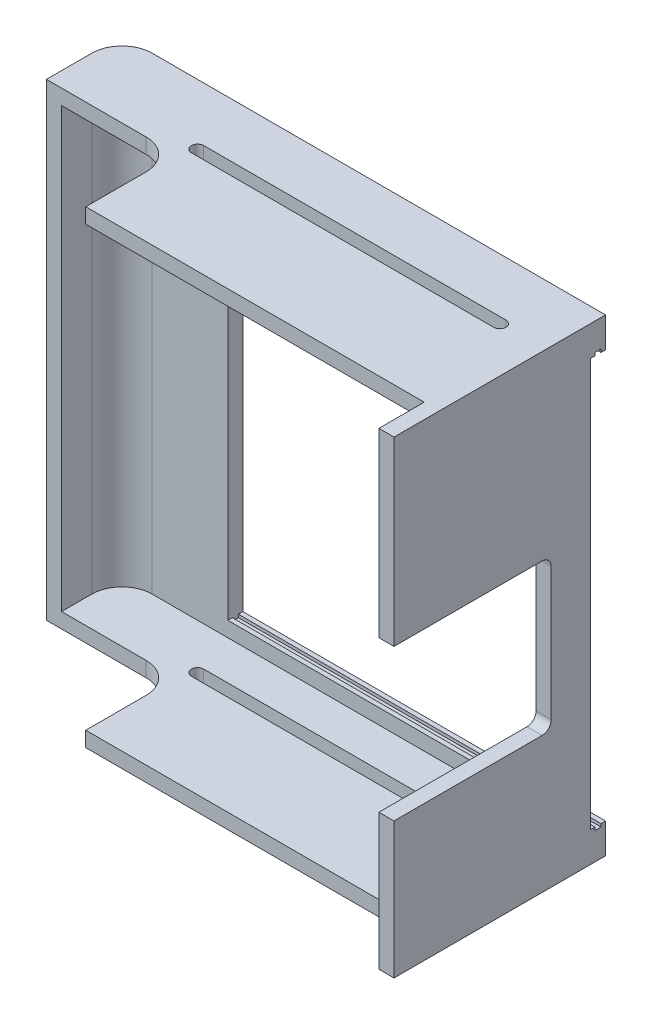
from build123d import *

# Parameters (mm, degrees)
BOSS_EXTRUDE1_DEPTH = 5
SKETCH2_W           = 150
SKETCH2_H           = 5
BOSS_EXTRUDE2_DEPTH = 145
SKETCH6_W           = 70
SKETCH6_H           = 155
BOSS_EXTRUDE3_DEPTH = 5
SKETCH7_W           = 52
SKETCH7_H           = 50
CUT_EXTRUDE1_DEPTH  = 5
SKETCH8_W           = 25
SKETCH8_H           = 155
BOSS_EXTRUDE4_DEPTH = 5
FILLET1_R           = 10
FILLET2_R           = 10
SKETCH9_W           = 2
SKETCH9_H           = 1
CUT_EXTRUDE2_DEPTH  = 120
FILLET5_R           = 3
CUT_EXTRUDE4_START  = -155
CUT_EXTRUDE4_DEPTH  = 155


with BuildPart() as part:
    # Sketch1 → Boss-Extrude1 (new body)
    with BuildSketch(Plane(origin=(0, 0, 0), x_dir=(1, 0, 0), z_dir=(0, 1, 0))):
        Polygon((63.462686567, 36.156716418), (-86.537313433, 36.156716418), (-86.537313433, 11.156716418), (-48.537313433, 11.156716418), (-48.537313433, -18.843283582), (63.462686567, -18.843283582), align=None)
    boss_extrude1 = extrude(amount=BOSS_EXTRUDE1_DEPTH)

    # Sketch2 → Boss-Extrude2 (add)
    with BuildSketch(Plane(origin=(0, 5, 0), x_dir=(1, 0, 0), z_dir=(0, 1, 0))):
        with Locations((-11.537313433, 33.656716418)):
            Rectangle(SKETCH2_W, SKETCH2_H)
    extrude(amount=BOSS_EXTRUDE2_DEPTH)

    # Mirror1: Boss-Extrude1 across plane
    add(boss_extrude1.mirror(Plane.ZX.offset(77.5)))

    # Sketch6 → Boss-Extrude3 (add)
    with BuildSketch(Plane(origin=(63.462686567, 0, 0), x_dir=(0, 0, -1), z_dir=(1, 0, 0))):
        with Locations((1.156716418, 77.5)):
            Rectangle(SKETCH6_W, SKETCH6_H)
    extrude(amount=BOSS_EXTRUDE3_DEPTH)

    # Sketch7 → Cut-Extrude1 (cut)
    with BuildSketch(Plane(origin=(68.462686567, 0, 0), x_dir=(0, 0, -1), z_dir=(1, 0, 0))):
        with Locations((-7.843283582, 70)):
            Rectangle(SKETCH7_W, SKETCH7_H)
    extrude(amount=-CUT_EXTRUDE1_DEPTH, mode=Mode.SUBTRACT)

    # Sketch8 → Boss-Extrude4 (add)
    with BuildSketch(Plane.ZY.offset(86.537313433)):
        with Locations((-23.656716418, 77.5)):
            Rectangle(SKETCH8_W, SKETCH8_H)
    extrude(amount=BOSS_EXTRUDE4_DEPTH)

    # Fillet1
    fillet1_edges = [part.edges().sort_by_distance(p)[0] for p in [
        (-48.537313433, 2.5, -11.156716418),
        (-48.537313433, 152.5, -11.156716418),
        (-91.537313433, 77.5, -36.156716418),
    ]]
    fillet(fillet1_edges, radius=FILLET1_R)

    # Fillet2
    fillet2_edges = [part.edges().sort_by_distance(p)[0] for p in [
        (-86.537313433, 77.5, -31.156716418),
    ]]
    fillet(fillet2_edges, radius=FILLET2_R)

    # Sketch9 → Cut-Extrude2 (cut)
    with BuildSketch(Plane(origin=(68.462686567, 0, 0), x_dir=(0, 0, -1), z_dir=(1, 0, 0))):
        Polygon((36.156716418, 10), (36.156716418, 145), (34.656716418, 145), (32.656716418, 145), (31.156716418, 145), (31.156716418, 10), (32.656716418, 10), (34.656716418, 10), align=None)
        with Locations((33.656716418, 9.5)):
            Rectangle(SKETCH9_W, SKETCH9_H)
        with Locations((33.656716418, 145.5)):
            Rectangle(SKETCH9_W, SKETCH9_H)
    extrude(amount=-CUT_EXTRUDE2_DEPTH, mode=Mode.SUBTRACT)

    # Fillet5
    fillet5_edges = [part.edges().sort_by_distance(p)[0] for p in [
        (65.962686567, 95, -18.156716418),
        (65.962686567, 45, -18.156716418),
    ]]
    fillet(fillet5_edges, radius=FILLET5_R)

    # Sketch11 → Cut-Extrude4 (cut)
    with BuildSketch(Plane.XZ.offset(CUT_EXTRUDE4_START)):
        with BuildLine():
            Line((53.462686567, -18.206716418), (-46.537313433, -18.206716418))
            ThreePointArc((-46.537313433, -18.206716418), (-48.587313433, -16.156716418), (-46.537313433, -14.106716418))
            Line((-46.537313433, -14.106716418), (53.462686567, -14.106716418))
            ThreePointArc((53.462686567, -14.106716418), (55.512686567, -16.156716418), (53.462686567, -18.206716418))
        make_face()
    extrude(amount=CUT_EXTRUDE4_DEPTH, mode=Mode.SUBTRACT)


solid = part.part
